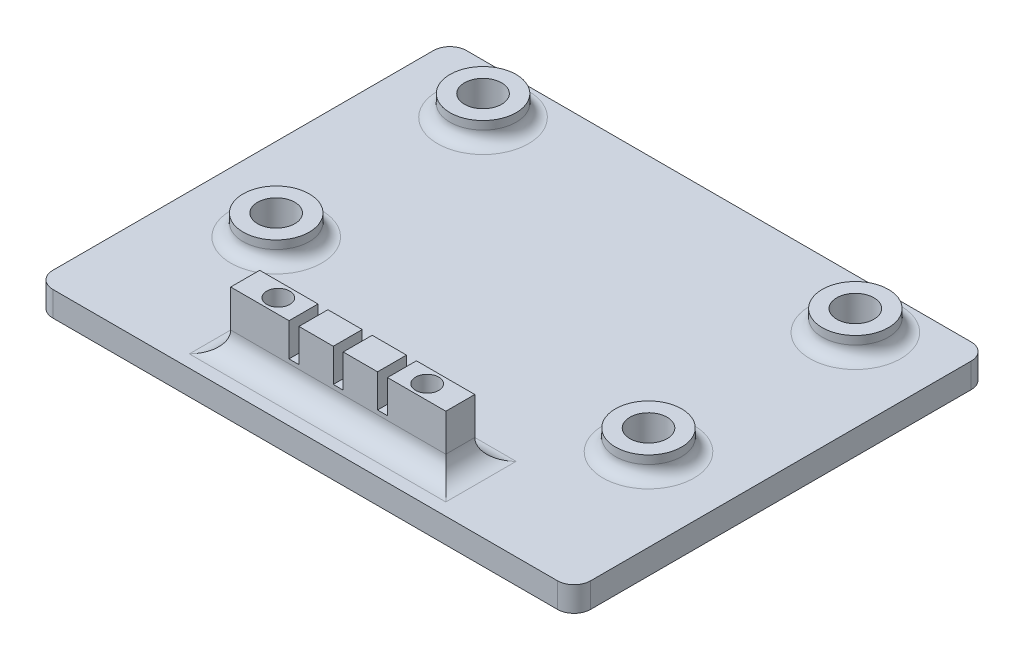
from build123d import *

# Parameters (mm, degrees)
SKIZZE1_W                                           = 65
SKIZZE1_H                                           = 50
AUFSATZ_LINEAR_AUSTRAGEN1_DEPTH                     = 3
VERRUNDUNG1_R                                       = 2
SKIZZE10_R                                          = 4
AUFSATZ_LINEAR_AUSTRAGEN4_DEPTH                     = 2.5
STIRNSENKUNG_F_R_M3_SENKSCHRAUBE_KOPF_B_D           = 4.5
STIRNSENKUNG_F_R_M3_SENKSCHRAUBE_KOPF_B_CBORE_D     = 4.9
STIRNSENKUNG_F_R_M3_SENKSCHRAUBE_KOPF_B_CBORE_DEPTH = 0.3
SKIZZE8_W                                           = 3.5
SKIZZE8_H                                           = 7
AUFSATZ_LINEAR_AUSTRAGEN3_DEPTH                     = 13
STIRNSENKUNG_F_R_M3_SENKSCHRAUBE_KO_2_D             = 2.8
STIRNSENKUNG_F_R_M3_SENKSCHRAUBE_KO_2_CBORE_D       = 6
STIRNSENKUNG_F_R_M3_SENKSCHRAUBE_KO_2_CBORE_DEPTH   = 6
SKIZZE7_W                                           = 1.2
SKIZZE7_H                                           = 3.5
SCHNITT_LINEAR_AUSTRAGEN1_DEPTH                     = 4
VERRUNDUNG2_R                                       = 1.5
VERRUNDUNG5_R                                       = 2.5
VERRUNDUNG6_R                                       = 2.5


with BuildPart() as part:
    # Skizze1 → Aufsatz-Linear austragen1 (new body)
    with BuildSketch(Plane(origin=(0, 0, 0), x_dir=(1, 0, 0), z_dir=(0, 1, 0))):
        with Locations((0, 25)):
            Rectangle(SKIZZE1_W, SKIZZE1_H)
    extrude(amount=AUFSATZ_LINEAR_AUSTRAGEN1_DEPTH)

    # Verrundung1
    verrundung1_edges = [part.edges().sort_by_distance(p)[0] for p in [
        (-32.5, 1.5, -50),
        (32.5, 1.5, -50),
        (32.5, 1.5, 0),
        (-32.5, 1.5, 0),
    ]]
    fillet(verrundung1_edges, radius=VERRUNDUNG1_R)

    # Skizze10 → Aufsatz-Linear austragen4 (add)
    with BuildSketch(Plane(origin=(0, 3, 0), x_dir=(1, 0, 0), z_dir=(0, 1, 0))):
        with Locations((-22.5, 44)):
            Circle(SKIZZE10_R)
        with Locations((-22.5, 19)):
            Circle(SKIZZE10_R)
        with Locations((22.5, 44)):
            Circle(SKIZZE10_R)
        with Locations((22.5, 19)):
            Circle(SKIZZE10_R)
    extrude(amount=AUFSATZ_LINEAR_AUSTRAGEN4_DEPTH)

    # Stirnsenkung f_r M3 Senkschraube _Kopf B (through all)
    with Locations(Plane.XZ):
        with Locations((-22.5, -19), (22.5, -44), (-22.5, -44), (22.5, -19)):
            CounterBoreHole(STIRNSENKUNG_F_R_M3_SENKSCHRAUBE_KOPF_B_D / 2, STIRNSENKUNG_F_R_M3_SENKSCHRAUBE_KOPF_B_CBORE_D / 2, STIRNSENKUNG_F_R_M3_SENKSCHRAUBE_KOPF_B_CBORE_DEPTH)

    # Skizze8 → Aufsatz-Linear austragen3 (add, symmetric)
    with BuildSketch(Plane(origin=(0, 0, 0), x_dir=(0, 0, -1), z_dir=(1, 0, 0))):
        with Locations((5.75, 6.5)):
            Rectangle(SKIZZE8_W, SKIZZE8_H)
    extrude(amount=AUFSATZ_LINEAR_AUSTRAGEN3_DEPTH, both=True)

    # Stirnsenkung f_r M3 Senkschraube _Ko 2 (through all)
    with Locations(Plane(origin=(0, -5, 1.917691722), x_dir=(-1, 0, 0), z_dir=(0, -1, 0))):
        with Locations((9, 7.667691722), (-9, 7.667691722)):
            CounterBoreHole(STIRNSENKUNG_F_R_M3_SENKSCHRAUBE_KO_2_D / 2, STIRNSENKUNG_F_R_M3_SENKSCHRAUBE_KO_2_CBORE_D / 2, STIRNSENKUNG_F_R_M3_SENKSCHRAUBE_KO_2_CBORE_DEPTH)

    # Skizze7 → Schnitt-Linear austragen1 (cut)
    with BuildSketch(Plane(origin=(0, 10, 0), x_dir=(1, 0, 0), z_dir=(0, 1, 0))):
        with Locations((0, 5.75)):
            Rectangle(SKIZZE7_W, SKIZZE7_H)
        with Locations((-5.35, 5.75)):
            Rectangle(SKIZZE7_W, SKIZZE7_H)
        with Locations((5.35, 5.75)):
            Rectangle(SKIZZE7_W, SKIZZE7_H)
    extrude(amount=-SCHNITT_LINEAR_AUSTRAGEN1_DEPTH, mode=Mode.SUBTRACT)

    # Verrundung2
    verrundung2_edges = [part.edges().sort_by_distance(p)[0] for p in [
        (-26.5, 3, -44),
        (-26.5, 3, -19),
        (18.5, 3, -44),
        (18.5, 3, -19),
    ]]
    fillet(verrundung2_edges, radius=VERRUNDUNG2_R)

    # Verrundung5
    verrundung5_edges = [part.edges().sort_by_distance(p)[0] for p in [
        (-13, 3, -5.75),
        (0, 3, -4),
        (13, 3, -5.75),
    ]]
    fillet(verrundung5_edges, radius=VERRUNDUNG5_R)

    # Verrundung6
    verrundung6_edges = [part.edges().sort_by_distance(p)[0] for p in [
        (0, 3, -7.5),
    ]]
    fillet(verrundung6_edges, radius=VERRUNDUNG6_R)


solid = part.part
